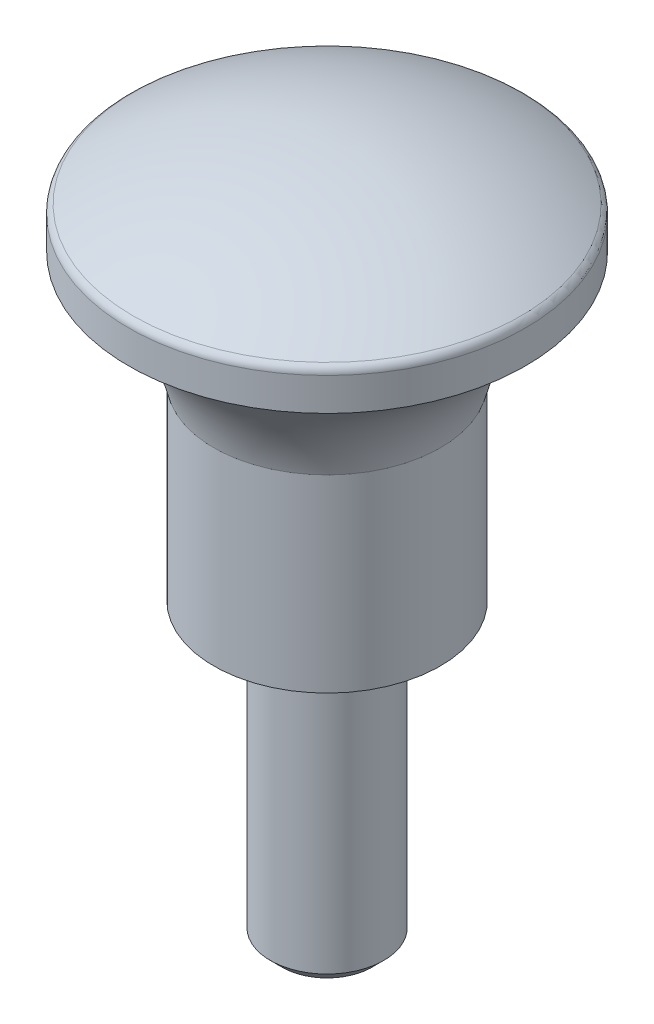
from build123d import *


with BuildPart() as part:
    # Esquisse1 → Révolution1 (revolve)
    with BuildSketch(Plane(origin=(0, 0, 0), x_dir=(0, 0, -1), z_dir=(1, 0, 0))):
        with BuildLine():
            Line((10.5, 23.354104043), (10.5, 21.613435))
            ThreePointArc((10.5, 21.613435), (7.595227269, 19.104514548), (6, 15.613435))
            Line((6, 15.613435), (6, 5.613435))
            Line((6, 5.613435), (3, 5.613435))
            Line((3, 5.613435), (3, -9.386565))
            Line((3, -9.386565), (2.386565, -10))
            Line((2.386565, -10), (0, -10))
            Line((0, -10), (0, 26.613435))
            ThreePointArc((0, 26.613435), (5.319852473, 25.892936282), (10.256410256, 23.783351967))
            ThreePointArc((10.256410256, 23.783351967), (10.434859246, 23.600878101), (10.5, 23.354104043))
        make_face()
    revolve(axis=Axis((0, -10, 0), (0, 1, 0)))


solid = part.part
